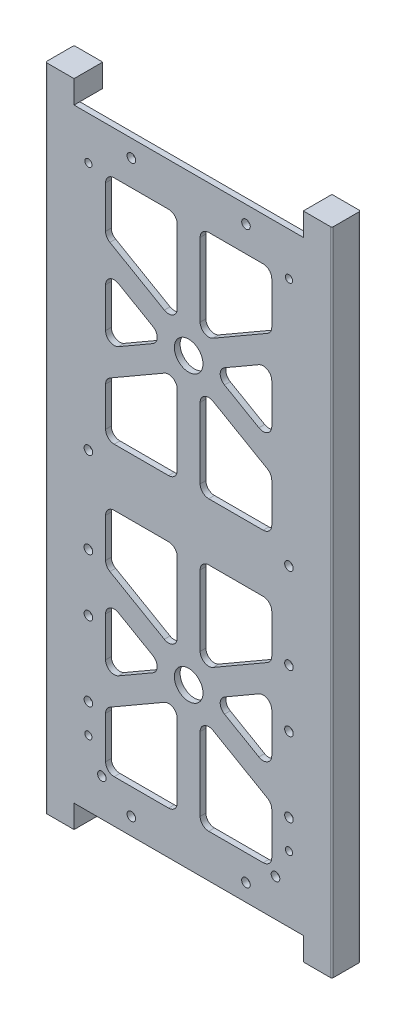
from build123d import *

# Parameters (mm, degrees)
SKETCH1_W                   = 88
SKETCH1_H                   = 211
BOSS_EXTRUDE1_DEPTH         = 2
CUT_EXTRUDE2_DEPTH          = 2
SKETCH4_R                   = 5
CUT_EXTRUDE3_DEPTH          = 3
FILLET2_R                   = 3
BOSS_EXTRUDE2_DEPTH         = 10
CUT_EXTRUDE5_DEPTH          = 8
SKETCH58_R                  = 1.665
CUT_EXTRUDE9_DEPTH          = 1.8
SKETCH59_R                  = 2
CUT_EXTRUDE10_DEPTH         = 10
FILLET3_R                   = 0.5
F_3_0MM_DOWEL_HOLE1_D       = 3
TAP_DRILL_FOR_M3X0_5_TAP1_D = 2.5


with BuildPart() as part:
    # Sketch1 → Boss-Extrude1 (new body)
    with BuildSketch(Plane.XY):
        with Locations((44, 105.5)):
            Rectangle(SKETCH1_W, SKETCH1_H)
    extrude(amount=BOSS_EXTRUDE1_DEPTH)

    # Sketch3 → Cut-Extrude2 (cut)
    with BuildSketch(Plane.XY.offset(2)):
        Polygon((73, 115.5), (73, 133.88804004), (48, 148.32179677), (48, 115.5), align=None)
        Polygon((40, 148.32179677), (15, 133.88804004), (15, 115.5), (40, 115.5), align=None)
        Polygon((36, 155.25), (15, 167.374355653), (15, 143.125644347), align=None)
        Polygon((73, 143.125644347), (73, 167.374355653), (52, 155.25), align=None)
        Polygon((73, 196), (48, 196), (48, 162.17820323), (73, 176.61195996), align=None)
        Polygon((40, 196), (15, 196), (15, 176.61195996), (40, 162.17820323), align=None)
    cut_extrude2 = extrude(amount=-CUT_EXTRUDE2_DEPTH, mode=Mode.SUBTRACT)

    # Sketch4 → Cut-Extrude3 (cut, through all)
    with BuildSketch(Plane.XY.offset(2)):
        with Locations((44, 155.25)):
            Circle(SKETCH4_R)
    cut_extrude3 = extrude(amount=-CUT_EXTRUDE3_DEPTH, mode=Mode.SUBTRACT)

    # Mirror2: Cut-Extrude2, Cut-Extrude3 across plane
    add(cut_extrude2.mirror(Plane(origin=(0, 105.5, 0), x_dir=(0, 0, 1), z_dir=(0, -1, 0))), mode=Mode.SUBTRACT)
    add(cut_extrude3.mirror(Plane(origin=(0, 105.5, 0), x_dir=(0, 0, 1), z_dir=(0, -1, 0))), mode=Mode.SUBTRACT)

    # Fillet2
    fillet2_edges = [part.edges().sort_by_distance(p)[0] for p in [
        (36, 55.75, 1),
        (15, 43.625644347, 1),
        (15, 67.874355653, 1),
        (40, 95.5, 1),
        (40, 62.67820323, 1),
        (15, 77.11195996, 1),
        (15, 95.5, 1),
        (48, 48.82179677, 1),
        (73, 34.38804004, 1),
        (73, 15, 1),
        (48, 15, 1),
        (73, 43.625644347, 1),
        (52, 55.75, 1),
        (73, 67.874355653, 1),
        (15, 15, 1),
        (15, 34.38804004, 1),
        (40, 48.82179677, 1),
        (40, 15, 1),
        (73, 77.11195996, 1),
        (48, 62.67820323, 1),
        (48, 95.5, 1),
        (73, 95.5, 1),
        (15, 167.374355653, 1),
        (36, 155.25, 1),
        (15, 143.125644347, 1),
        (40, 148.32179677, 1),
        (40, 115.5, 1),
        (15, 115.5, 1),
        (15, 133.88804004, 1),
        (73, 176.61195996, 1),
        (48, 162.17820323, 1),
        (48, 196, 1),
        (73, 196, 1),
        (52, 155.25, 1),
        (73, 167.374355653, 1),
        (73, 143.125644347, 1),
        (15, 176.61195996, 1),
        (15, 196, 1),
        (40, 196, 1),
        (40, 162.17820323, 1),
        (48, 148.32179677, 1),
        (73, 133.88804004, 1),
        (73, 115.5, 1),
        (48, 115.5, 1),
    ]]
    fillet(fillet2_edges, radius=FILLET2_R)

    # Sketch7 → Boss-Extrude2 (add)
    with BuildSketch(Plane.XY.offset(2)):
        Polygon((94, 219), (84, 219), (84, 211), (88, 211), (88, 0), (84, 0), (84, -8), (94, -8), align=None)
        Polygon((-6, -8), (4, -8), (4, 0), (0, 0), (0, 211), (4, 211), (4, 219), (-6, 219), align=None)
    extrude(amount=-BOSS_EXTRUDE2_DEPTH)

    # Sketch53 → Cut-Extrude5 (cut)
    with BuildSketch(Plane(origin=(0, 0, -8), x_dir=(-1, 0, 0), z_dir=(0, 0, -1))):
        with BuildLine():
            Line((-90, 0), (-88, 0))
            Line((-88, 0), (-88, 211))
            Line((-88, 211), (-90, 211))
            ThreePointArc((-90, 211), (-91.414213562, 210.414213562), (-92, 209))
            Line((-92, 209), (-92, 2))
            ThreePointArc((-92, 2), (-91.414213562, 0.585786438), (-90, 0))
        make_face()
        with BuildLine():
            Line((2, 0), (-4, 0))
            Line((-4, 0), (-4, 211))
            Line((-4, 211), (2, 211))
            ThreePointArc((2, 211), (3.414213562, 210.414213562), (4, 209))
            Line((4, 209), (4, 2))
            ThreePointArc((4, 2), (3.414213562, 0.585786438), (2, 0))
        make_face()
    extrude(amount=-CUT_EXTRUDE5_DEPTH, mode=Mode.SUBTRACT)

    # Sketch58 → Cut-Extrude9 (cut)
    with BuildSketch(Plane(origin=(0, 0, 0), x_dir=(-1, 0, 0), z_dir=(0, 0, -1))):
        with Locations((-0.7, 13)):
            Circle(SKETCH58_R)
    cut_extrude9 = extrude(amount=-CUT_EXTRUDE9_DEPTH, mode=Mode.SUBTRACT)

    # Mirror4: Cut-Extrude9 across plane
    add(cut_extrude9.mirror(Plane(origin=(44, 0, 0), x_dir=(0, 0, 1), z_dir=(1, 0, 0))), mode=Mode.SUBTRACT)

    # Sketch59 → Cut-Extrude10 (cut)
    with BuildSketch(Plane(origin=(0, -8, 0), x_dir=(-1, 0, 0), z_dir=(0, -1, 0))):
        with Locations((-89, 2.4)):
            Circle(SKETCH59_R)
        with Locations((1, 2.4)):
            Circle(SKETCH59_R)
    extrude(amount=-CUT_EXTRUDE10_DEPTH, mode=Mode.SUBTRACT)

    # Fillet3
    fillet3_edges = [part.edges().sort_by_distance(p)[0] for p in [
        (94, 105.5, -8),
        (94, 105.5, 2),
        (-6, 105.5, -8),
        (-6, 105.5, 2),
    ]]
    fillet(fillet3_edges, radius=FILLET3_R)

    # Ø3.0mm Dowel Hole1 (through all)
    with Locations(Plane.XY.offset(2)):
        with Locations((24, 205), (64, 205), (9, 109.2), (79, 109.2), (9, 79.2), (79, 79.2), (9, 59.2), (79, 59.2), (9, 33.2), (79, 33.2), (13.7, 13), (24, 6), (74.3, 13), (64, 6)):
            Hole(F_3_0MM_DOWEL_HOLE1_D / 2)

    # Tap Drill for M3x0.5 Tap1 (through all)
    with Locations(Plane.XY.offset(2)):
        with Locations((9, 196), (79, 196), (9, 23), (79, 23)):
            Hole(TAP_DRILL_FOR_M3X0_5_TAP1_D / 2)


solid = part.part
